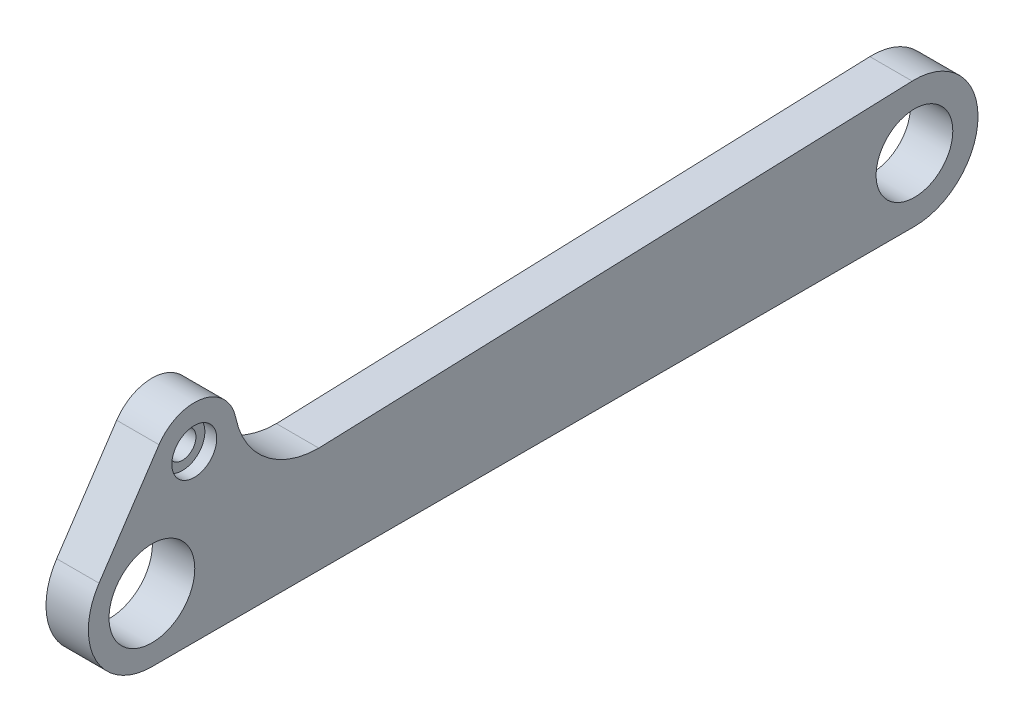
from build123d import *

# Parameters (mm, degrees)
SKETCH_1_R          = 2.5
SKETCH_1_R_2        = 2.05
EXTRUDE_1_DEPTH     = 5
SKETCH_2_R          = 2.5
EXTRUDE_2_DEPTH     = 5
FILLET_1_R          = 6
FILLET_2_R          = 10
SKETCH_3_R          = 1.6
EXTRUDE_3_DEPTH     = 5
FILLET_3_R          = 10
SKETCH_4_W          = 47.859617289
SKETCH_4_H          = 15
CUT_EXTRUDE_1_DEPTH = 6.0000001
SKETCH_6_R          = 2.65
CUT_EXTRUDE_2_DEPTH = 1.4
EXTRUDE_5_DEPTH     = 5
SKETCH_11_R         = 4.525
CUT_EXTRUDE_4_DEPTH = 6.0000001
SKETCH_13_R         = 5.06
CUT_EXTRUDE_5_DEPTH = 5


with BuildPart() as part:
    # 草图1 → 凸台-拉伸1 (new body)
    with BuildSketch(Plane(origin=(0, 0, 0), x_dir=(0, 0, -1), z_dir=(1, 0, 0))):
        with BuildLine():
            Line((0, 5), (90, 5))
            ThreePointArc((90, 5), (95, 0), (90, -5))
            Line((90, -5), (0, -5))
            ThreePointArc((0, -5), (-5, 0), (0, 5))
        make_face()
        Circle(SKETCH_1_R, mode=Mode.SUBTRACT)
        with Locations((90, 0)):
            Circle(SKETCH_1_R_2, mode=Mode.SUBTRACT)
    extrude(amount=EXTRUDE_1_DEPTH)

    # 草图2 → 凸台-拉伸2 (add)
    with BuildSketch(Plane(origin=(5, 0, 0), x_dir=(0, 0, -1), z_dir=(1, 0, 0))):
        with BuildLine():
            Line((49.91480075, 7.043176995), (48.200371687, 5))
            Line((48.200371687, 5), (36.190624625, 5))
            Line((36.190624625, 5), (42.867191873, 12.956823005))
            ThreePointArc((42.867191873, 12.956823005), (49.347819316, 13.523804438), (49.91480075, 7.043176995))
        make_face()
        with Locations((46.390996312, 10)):
            Circle(SKETCH_2_R, mode=Mode.SUBTRACT)
    extrude(amount=-EXTRUDE_2_DEPTH)

    # 圆角1
    fillet_1_edges = [part.edges().sort_by_distance(p)[0] for p in [
        (2.5, 5, -48.200371687),
    ]]
    fillet(fillet_1_edges, radius=FILLET_1_R)

    # 圆角2
    fillet_2_edges = [part.edges().sort_by_distance(p)[0] for p in [
        (2.5, 5, -36.190624625),
    ]]
    fillet(fillet_2_edges, radius=FILLET_2_R)

    # 草图3 → 凸台-拉伸3 (add)
    with BuildSketch(Plane(origin=(5, 0, 0), x_dir=(0, 0, -1), z_dir=(1, 0, 0))):
        with BuildLine():
            Line((-4.615384615, 1.923076923), (0.384615385, 13.923076923))
            ThreePointArc((0.384615385, 13.923076923), (6.923076923, 16.615384615), (9.615384615, 10.076923077))
            Line((9.615384615, 10.076923077), (7.5, 5))
            Line((7.5, 5), (0, 5))
            ThreePointArc((0, 5), (-2.773500981, 4.160251472), (-4.615384615, 1.923076923))
        make_face()
        with Locations((5, 12)):
            Circle(SKETCH_3_R, mode=Mode.SUBTRACT)
    extrude(amount=-EXTRUDE_3_DEPTH)

    # 圆角3
    fillet_3_edges = [part.edges().sort_by_distance(p)[0] for p in [
        (2.5, 5, -7.5),
    ]]
    fillet(fillet_3_edges, radius=FILLET_3_R)

    # 草图4 → 切除-拉伸1 (cut, through all)
    with BuildSketch(Plane(origin=(5, 0, 0), x_dir=(0, 0, -1), z_dir=(1, 0, 0))):
        with Locations((49.542051895, 12.5)):
            Rectangle(SKETCH_4_W, SKETCH_4_H)
    extrude(amount=-CUT_EXTRUDE_1_DEPTH, mode=Mode.SUBTRACT)

    # 草图6 → 切除-拉伸2 (cut)
    with BuildSketch(Plane(origin=(5, 0, 0), x_dir=(0, 0, -1), z_dir=(1, 0, 0))):
        with Locations((5, 12)):
            Circle(SKETCH_6_R)
    extrude(amount=-CUT_EXTRUDE_2_DEPTH, mode=Mode.SUBTRACT)

    # 草图10 → 凸台-拉伸5 (add)
    with BuildSketch(Plane(origin=(5, 0, 0), x_dir=(0, 0, -1), z_dir=(1, 0, 0))):
        with BuildLine():
            Line((89.732959314, 7.495244444), (19.696938457, 5))
            Line((19.696938457, 5), (90, 5))
            ThreePointArc((90, 5), (95, 0), (90, -5))
            Line((90, -5), (0, -5))
            ThreePointArc((0, -5), (-4.160251472, -2.773500981), (-4.615384615, 1.923076923))
            Line((-4.615384615, 1.923076923), (0.384615385, 13.923076923))
            ThreePointArc((0.384615385, 13.923076923), (0.591982965, 14.359954623), (0.840585507, 14.774756039))
            Line((0.840585507, 14.774756039), (-6.23912174, 4.162134058))
            ThreePointArc((-6.23912174, 4.162134058), (-6.613093279, -3.537936868), (0, -7.5))
            Line((0, -7.5), (90, -7.5))
            ThreePointArc((90, -7.5), (97.498811017, 0.133541513), (89.732959314, 7.495244444))
        make_face()
    extrude(amount=-EXTRUDE_5_DEPTH)

    # 草图11 → 切除-拉伸4 (cut, through all)
    with BuildSketch(Plane(origin=(5, 0, 0), x_dir=(0, 0, -1), z_dir=(1, 0, 0))):
        with Locations((90, 0)):
            Circle(SKETCH_11_R)
    extrude(amount=-CUT_EXTRUDE_4_DEPTH, mode=Mode.SUBTRACT)

    # 草图13 → 切除-拉伸5 (cut)
    with BuildSketch(Plane(origin=(5, 0, 0), x_dir=(0, 0, -1), z_dir=(1, 0, 0))):
        Circle(SKETCH_13_R)
    extrude(amount=-CUT_EXTRUDE_5_DEPTH, mode=Mode.SUBTRACT)


solid = part.part
